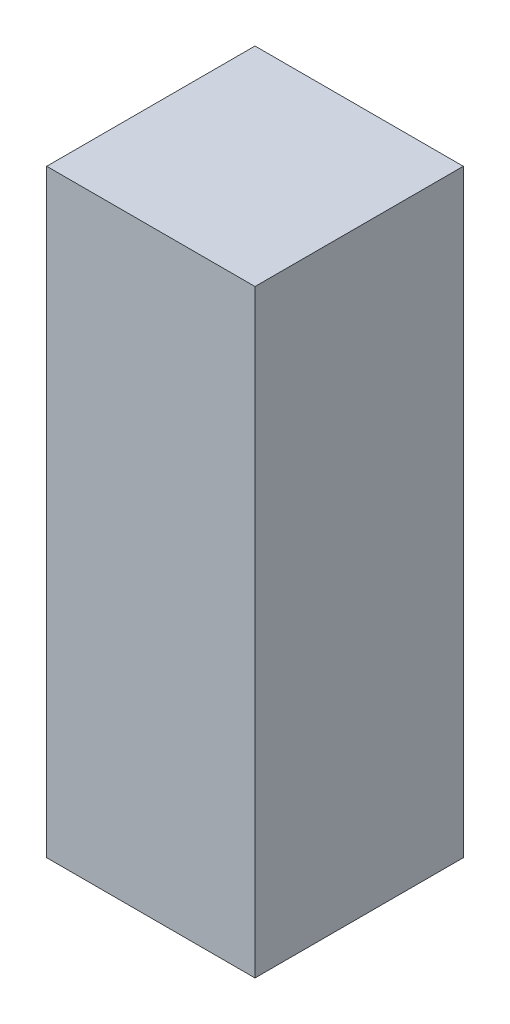
from build123d import *

# Parameters (mm, degrees)
SKETCH_1_W            = 40
SKETCH_1_H            = 115
EXTRUDE_1_DEPTH       = 40
HOLE_WIZARD_M31_D     = 3.4
HOLE_WIZARD_M31_DEPTH = 5
HOLE_WIZARD_M31_TIP   = 1.021463052
HOLE_WIZARD_M61_D     = 6.6
HOLE_WIZARD_M61_DEPTH = 5
HOLE_WIZARD_M61_TIP   = 1.982840043


with BuildPart() as part:
    # Эскиз1 → Бобышка-Вытянуть1 (new body)
    with BuildSketch(Plane(origin=(0, 0, 0), x_dir=(0, 0, -1), z_dir=(1, 0, 0))):
        with Locations((-23.3234714, -21.208086785)):
            Rectangle(SKETCH_1_W, SKETCH_1_H)
    extrude(amount=EXTRUDE_1_DEPTH)

    # Отверстие с зазором M31
    with Locations(Plane(origin=(0, 0, 3.3234714), x_dir=(-1, 0, 0), z_dir=(0, 0, -1))):
        with Locations((-20, -24.708086785)):
            Hole(HOLE_WIZARD_M31_D / 2, depth=HOLE_WIZARD_M31_DEPTH)
            with Locations((0, 0, -(HOLE_WIZARD_M31_DEPTH + HOLE_WIZARD_M31_TIP / 2))):  # 118° drill point
                Cone(0, HOLE_WIZARD_M31_D / 2, HOLE_WIZARD_M31_TIP, mode=Mode.SUBTRACT)

    # Отверстие с зазором M61
    with Locations(Plane(origin=(0, 0, 3.3234714), x_dir=(-1, 0, 0), z_dir=(0, 0, -1))):
        with Locations((-20, -43.708086785)):
            Hole(HOLE_WIZARD_M61_D / 2, depth=HOLE_WIZARD_M61_DEPTH)
            with Locations((0, 0, -(HOLE_WIZARD_M61_DEPTH + HOLE_WIZARD_M61_TIP / 2))):  # 118° drill point
                Cone(0, HOLE_WIZARD_M61_D / 2, HOLE_WIZARD_M61_TIP, mode=Mode.SUBTRACT)


solid = part.part
